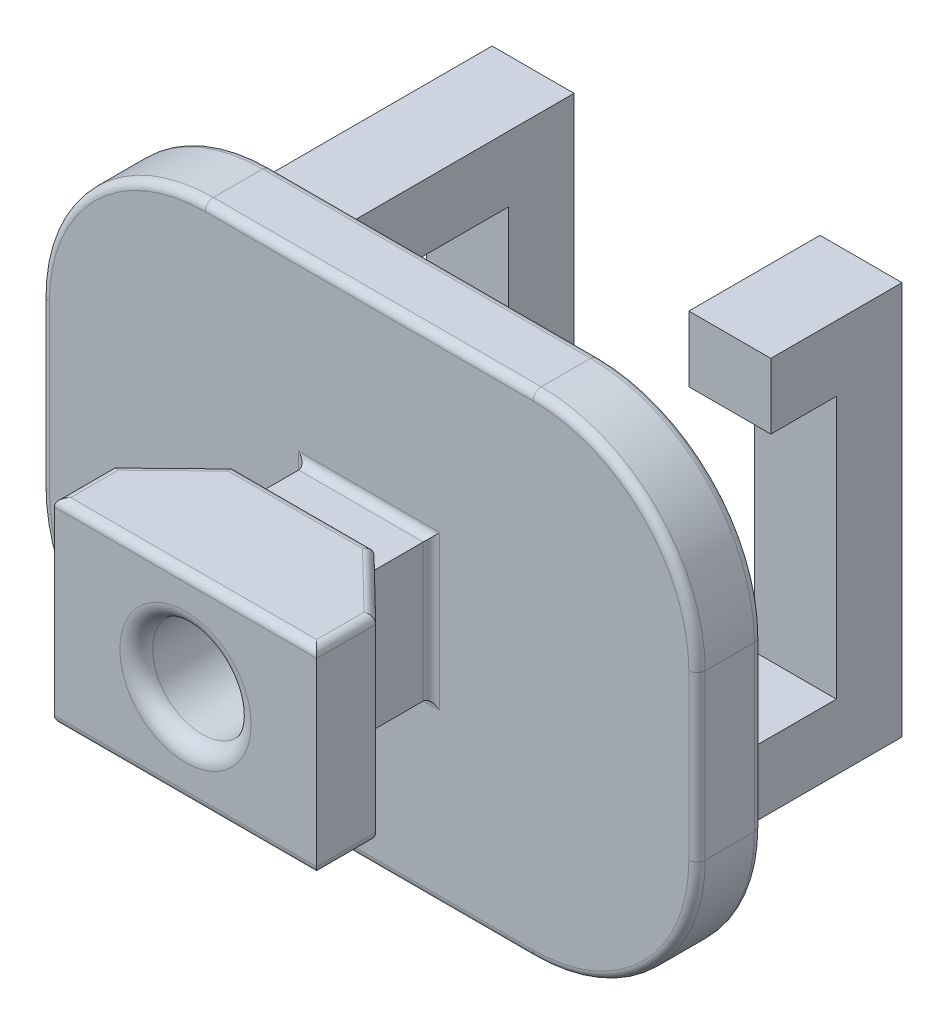
from build123d import *

# Parameters (mm, degrees)
BOSS_EXTRUDE1_DEPTH = 6
SKETCH2_W           = 7.6
SKETCH2_H           = 8.4
BOSS_EXTRUDE2_DEPTH = 4
SKETCH3_W           = 40
SKETCH3_H           = 30
BOSS_EXTRUDE3_DEPTH = 4
BOSS_EXTRUDE4_DEPTH = 2.5
BOSS_EXTRUDE5_DEPTH = 2.5
FILLET1_R           = 10
SKETCH8_R           = 3
CUT_EXTRUDE1_DEPTH  = 32.2
FILLET2_R           = 1
FILLET3_R           = 0.5
FILLET4_R           = 0.5
FILLET5_R           = 0.5


with BuildPart() as part:
    # Sketch1 → Boss-Extrude1 (new body, symmetric)
    with BuildSketch(Plane(origin=(0, 0, 0), x_dir=(1, 0, 0), z_dir=(0, 1, 0))):
        Polygon((-8, 0), (8, 0), (8, 3.6), (4.3, 7.2), (-4.3, 7.2), (-8, 3.6), align=None)
    extrude(amount=BOSS_EXTRUDE1_DEPTH, both=True)

    # Sketch2 → Boss-Extrude2 (add)
    with BuildSketch(Plane(origin=(0, 0, -7.2), x_dir=(-1, 0, 0), z_dir=(0, 0, -1))):
        Rectangle(SKETCH2_W, SKETCH2_H)
    extrude(amount=BOSS_EXTRUDE2_DEPTH)

    # Sketch3 → Boss-Extrude3 (add)
    with BuildSketch(Plane(origin=(0, 0, -11.2), x_dir=(-1, 0, 0), z_dir=(0, 0, -1))):
        Rectangle(SKETCH3_W, SKETCH3_H)
    extrude(amount=BOSS_EXTRUDE3_DEPTH)

    # Sketch6 → Boss-Extrude4 (add, symmetric)
    with BuildSketch(Plane.ZY.offset(10)):
        Polygon((-27.2, 8), (-15.2, 8), (-15.2, 12), (-31.2, 12), (-31.2, -12), (-23.2, -12), (-23.2, -8), (-27.2, -8), align=None)
    extrude(amount=BOSS_EXTRUDE4_DEPTH, both=True)

    # Sketch7 → Boss-Extrude5 (add, symmetric)
    with BuildSketch(Plane(origin=(10, 0, 0), x_dir=(0, 0, -1), z_dir=(1, 0, 0))):
        Polygon((23.2, 12), (23.2, 8), (27.2, 8), (27.2, -8), (15.2, -8), (15.2, -12), (31.2, -12), (31.2, 12), align=None)
    extrude(amount=BOSS_EXTRUDE5_DEPTH, both=True)

    # Fillet1
    fillet1_edges = [part.edges().sort_by_distance(p)[0] for p in [
        (-20, -15, -13.2),
        (-20, 15, -13.2),
        (20, 15, -13.2),
        (20, -15, -13.2),
    ]]
    fillet(fillet1_edges, radius=FILLET1_R)

    # Sketch8 → Cut-Extrude1 (cut, through all)
    with BuildSketch(Plane.XY):
        Circle(SKETCH8_R)
    extrude(amount=-CUT_EXTRUDE1_DEPTH, mode=Mode.SUBTRACT)

    # Fillet2
    fillet2_edges = [part.edges().sort_by_distance(p)[0] for p in [
        (-3, 0, -15.2),
        (-3, 0, 0),
    ]]
    fillet(fillet2_edges, radius=FILLET2_R)

    # Fillet3
    fillet3_edges = [part.edges().sort_by_distance(p)[0] for p in [
        (-6.15, 6, -5.4),
        (-8, 6, -1.8),
        (0, 6, 0),
        (8, 6, -1.8),
        (6.15, 6, -5.4),
        (8, -6, -1.8),
        (0, -6, 0),
        (-8, -6, -1.8),
        (-6.15, -6, -5.4),
        (0, -6, -7.2),
        (6.15, -6, -5.4),
        (0, 6, -7.2),
    ]]
    fillet(fillet3_edges, radius=FILLET3_R)

    # Fillet4
    fillet4_edges = [part.edges().sort_by_distance(p)[0] for p in [
        (-20, 0, -11.2),
        (-20, 0, -15.2),
        (0, -15, -11.2),
        (20, 0, -11.2),
        (0, 15, -11.2),
        (17.071067812, 12.071067812, -11.2),
        (17.071067812, -12.071067812, -11.2),
        (-17.071067812, 12.071067812, -11.2),
        (-17.071067812, -12.071067812, -11.2),
        (0, -15, -15.2),
        (0, 15, -15.2),
        (20, 0, -15.2),
        (17.071067812, 12.071067812, -15.2),
        (17.071067812, -12.071067812, -15.2),
        (-17.071067812, 12.071067812, -15.2),
        (-17.071067812, -12.071067812, -15.2),
    ]]
    fillet(fillet4_edges, radius=FILLET4_R)

    # Fillet5
    fillet5_edges = [part.edges().sort_by_distance(p)[0] for p in [
        (-3.8, 0, -11.2),
        (0, 4.2, -11.2),
        (3.8, 0, -11.2),
        (0, -4.2, -11.2),
    ]]
    fillet(fillet5_edges, radius=FILLET5_R)


solid = part.part
